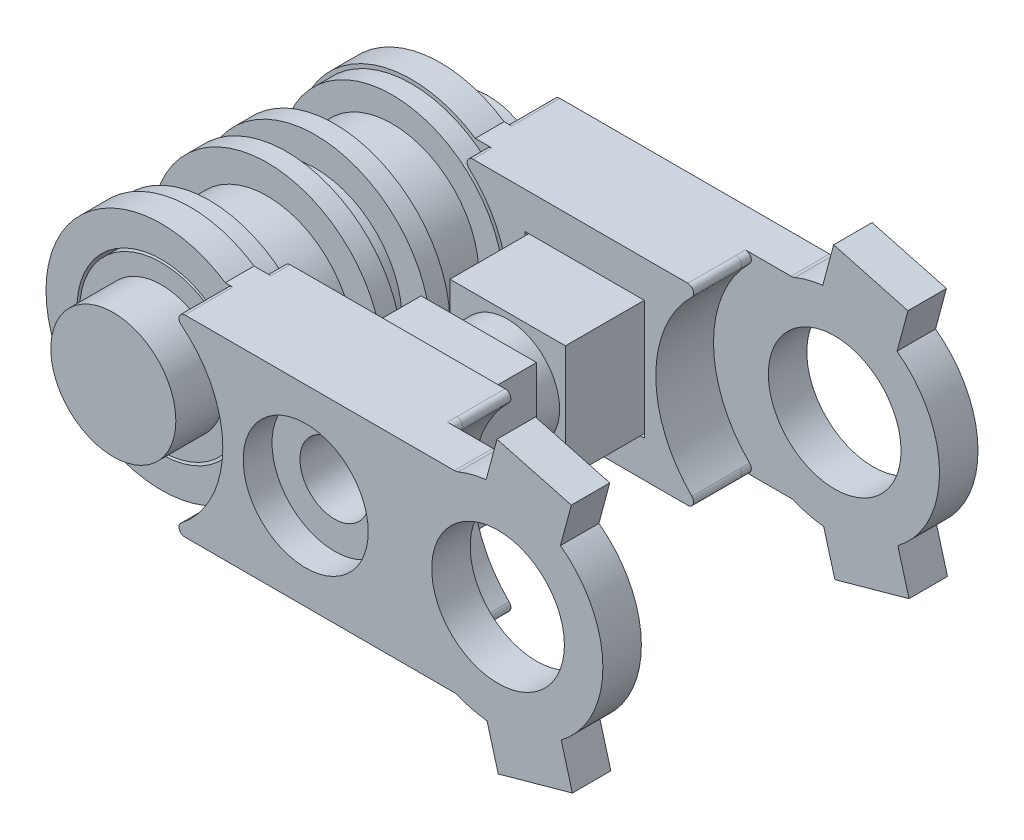
from build123d import *

# Parameters (mm, degrees)
SKETCH_1_R               = 4.5
EXTRUDE_1_DEPTH          = 3
SKETCH_2_R               = 6
EXTRUDE_2_DEPTH          = 1
EXTRUDE_START            = 1.5
SKETCH_3_R               = 4.5
EXTRUDE_3_DEPTH          = 1.5
SKETCH_4_R               = 6.000000000000001
EXTRUDE_4_DEPTH          = 1
EXTRUDE_START_2          = 3
SKETCH_5_R               = 4.5
EXTRUDE_5_DEPTH          = 3
SKETCH_6_R               = 6.000000000000001
EXTRUDE_6_DEPTH          = 1
EXTRUDE_START_3          = 1
SKETCH_7_R               = 6.000000000000001
EXTRUDE_7_DEPTH          = 1
SKETCH_10_R              = 4.25
EXTRUDE_10_DEPTH         = 1.5
SKETCH_11_R              = 3.25
EXTRUDE_11_DEPTH         = 2.5
SKETCH_12_R              = 4.390000000000002
EXTRUDE_12_DEPTH         = 1.5
EXTRUDE_13_DEPTH         = 0.5
FILLET_9_R               = 0.3
SKETCH_14_R              = 3.450000000000003
EXTRUDE_14_DEPTH         = 2
EXTRUDE_15_DEPTH         = 1
SKETCH_16_R              = 1.799999999999999
CUT_EXTRUDE_1_DEPTH      = 33.61828474950821
CUT_EXTRUDE_2_DEPTH      = 2
EXTRUDE_16_DEPTH         = 11.5
SKETCH_19_R              = 1.799999999999999
CUT_EXTRUDE_3_DEPTH      = 30.89903844607716
CUT_EXTRUDE_4_DEPTH      = 0.75
CUT_EXTRUDE_4_DEPTH_BACK = 0.75
SKETCH_20_R              = 2.6999999999999993
SKETCH_21_R              = 3.2500000000000027
CUT_EXTRUDE_5_DEPTH      = 1.5
CUT_EXTRUDE_6_DEPTH      = 1
EXTRUDE_17_DEPTH         = 2
EXTRUDE_18_DEPTH         = 2
SKETCH_26_R              = 6.000000000000001
SKETCH_26_R_2            = 5.800000000000002
CUT_EXTRUDE_8_DEPTH      = 31.24094733315028
SKETCH_27_R              = 6.000000000000001
SKETCH_27_R_2            = 5.8000000000000025
CUT_EXTRUDE_9_DEPTH      = 31.24094733315028


with BuildPart() as part:
    # ｽｹｯﾁ1 → ﾎﾞｽ - 押し出し1 (new body)
    with BuildSketch(Plane.XY):
        Circle(SKETCH_1_R)
    extrude(amount=EXTRUDE_1_DEPTH)

    # ｽｹｯﾁ2 → ﾎﾞｽ - 押し出し2 (add)
    with BuildSketch(Plane(origin=(0, 0, 0), x_dir=(-1, 0, 0), z_dir=(0, 0, -1))):
        Circle(SKETCH_2_R)
    extrude(amount=EXTRUDE_2_DEPTH)

    # ｽｹｯﾁ3 → ﾎﾞｽ - 押し出し3 (add)
    with BuildSketch(Plane(origin=(0, 0, -1), x_dir=(-1, 0, 0), z_dir=(0, 0, -1)).offset(EXTRUDE_START)):
        with Locations(Location((0, 0, 0), (0, 0, 180))):
            Circle(SKETCH_3_R)
    extrude(amount=-EXTRUDE_3_DEPTH)

    # ｽｹｯﾁ4 → ﾎﾞｽ - 押し出し4 (add)
    with BuildSketch(Plane(origin=(0, 0, -2.5), x_dir=(-1, 0, 0), z_dir=(0, 0, -1))):
        Circle(SKETCH_4_R)
    extrude(amount=EXTRUDE_4_DEPTH)

    # ｽｹｯﾁ5 → ﾎﾞｽ - 押し出し5 (add)
    with BuildSketch(Plane(origin=(0, 0, -3.5), x_dir=(-1, 0, 0), z_dir=(0, 0, -1)).offset(EXTRUDE_START_2)):
        with Locations(Location((0, 0, 0), (0, 0, 180))):
            Circle(SKETCH_5_R)
    extrude(amount=-EXTRUDE_5_DEPTH)

    # ｽｹｯﾁ6 → ﾎﾞｽ - 押し出し6 (add)
    with BuildSketch(Plane(origin=(0, 0, -6.500000000000001), x_dir=(-1, 0, 0), z_dir=(0, 0, -1))):
        Circle(SKETCH_6_R)
    extrude(amount=EXTRUDE_6_DEPTH)

    # ｽｹｯﾁ7 → ﾎﾞｽ - 押し出し7 (add)
    with BuildSketch(Plane.XY.offset(3).offset(EXTRUDE_START_3)):
        with Locations(Location((0, 0, 0), (0, 0, 180))):
            Circle(SKETCH_7_R)
    extrude(amount=-EXTRUDE_7_DEPTH)

    # ｽｹｯﾁ10 → ﾎﾞｽ - 押し出し10 (add)
    with BuildSketch(Plane.XY.offset(4)):
        Circle(SKETCH_10_R)
    extrude_10 = extrude(amount=EXTRUDE_10_DEPTH)

    # ｽｹｯﾁ11 → ﾎﾞｽ - 押し出し11 (add)
    with BuildSketch(Plane.XY.offset(5.5)):
        Circle(SKETCH_11_R)
    extrude_11 = extrude(amount=EXTRUDE_11_DEPTH)

    # ﾐﾗｰ1: ﾎﾞｽ - 押し出し10, ﾎﾞｽ - 押し出し11 across plane
    add(extrude_10.mirror(Plane.XY.offset(-1.7500000000000002)))
    add(extrude_11.mirror(Plane.XY.offset(-1.7500000000000002)))

    # ｽｹｯﾁ26 → ｶｯﾄ - 押し出し8 (cut, through all)
    with BuildSketch(Plane(origin=(0, 0, 3), x_dir=(-1, 0, 0), z_dir=(0, 0, -1))):
        Circle(SKETCH_26_R)
        Circle(SKETCH_26_R_2, mode=Mode.SUBTRACT)
    extrude(amount=-CUT_EXTRUDE_8_DEPTH, mode=Mode.SUBTRACT)

    # ｽｹｯﾁ27 → ｶｯﾄ - 押し出し9 (cut, through all)
    with BuildSketch(Plane.XY.offset(-6.500000000000001)):
        with Locations(Location((0, 0, 0), (0, 0, 180))):
            Circle(SKETCH_27_R)
        with Locations(Location((0, 0, 0), (0, 0, 180))):
            Circle(SKETCH_27_R_2, mode=Mode.SUBTRACT)
    extrude(amount=-CUT_EXTRUDE_9_DEPTH, mode=Mode.SUBTRACT)


with BuildPart() as body_2:
    # ｽｹｯﾁ12 → ﾎﾞｽ - 押し出し12 (new body)
    with BuildSketch(Plane.XY.offset(4)):
        with BuildLine():
            Line((3.3166247903554016, 5), (16.167246420652642, 5))
            ThreePointArc((16.167246420652642, 5), (13.700000000000001, 3.57e-15), (16.16724642065264, -5))
            Line((16.16724642065264, -5), (3.3166247903553985, -5.000000000000003))
            ThreePointArc((3.3166247903553985, -5.000000000000003), (-6.000000000000001, 7.3e-16), (3.3166247903554016, 5))
        make_face()
        Circle(SKETCH_12_R, mode=Mode.SUBTRACT)
    extrude(amount=EXTRUDE_12_DEPTH)

    # ｽｹｯﾁ13 → ﾎﾞｽ - 押し出し13 (add)
    with BuildSketch(Plane.XY.offset(5.5)):
        with BuildLine():
            Line((15.366426864718767, 5.000000000000001), (3.71350238992787, 4.999999999999999))
            ThreePointArc((3.71350238992787, 4.999999999999999), (3.4301142319534543, 4.798443648448575), (3.5275172952737197, 4.464607679465777))
            ThreePointArc((3.5275172952737197, 4.464607679465777), (5.69, 3.16e-15), (3.527517295273725, -4.464607679465773))
            ThreePointArc((3.527517295273725, -4.464607679465773), (3.4301142319534588, -4.798443648448569), (3.713502389927875, -4.9999999999999964))
            Line((3.713502389927875, -4.9999999999999964), (15.366426864718758, -4.999999999999996))
            ThreePointArc((15.366426864718758, -4.999999999999996), (15.643997494550977, -4.813818036595895), (15.57704382541336, -4.486363636363631))
            ThreePointArc((15.57704382541336, -4.486363636363631), (13.7, 6.37e-15), (15.577043825413366, 4.486363636363639))
            ThreePointArc((15.577043825413366, 4.486363636363639), (15.643997494550984, 4.813818036595901), (15.366426864718767, 5.000000000000001))
        make_face()
    extrude(amount=EXTRUDE_13_DEPTH)

    # ﾌｨﾚｯﾄ9
    fillet_9_edges = [body_2.edges().sort_by_distance(p)[0] for p in [
        (16.16724642065264, -5.000000000000001, 4.75),
        (16.167246420652642, 5, 4.75),
    ]]
    fillet(fillet_9_edges, radius=FILLET_9_R)

    # ｽｹｯﾁ14 → ﾎﾞｽ - 押し出し14 (add)
    with BuildSketch(Plane.XY.offset(6)):
        with BuildLine():
            Line((3.71350238992787, 5), (17.73008810743677, 5))
            ThreePointArc((17.73008810743677, 5), (17.827318665969592, 5.00954488636839), (17.920837005971492, 5.03781512605042))
            ThreePointArc((17.920837005971492, 5.03781512605042), (25.45, 2.42e-15), (17.920837005971496, -5.037815126050422))
            ThreePointArc((17.920837005971496, -5.037815126050422), (17.827318665969596, -5.009544886368393), (17.730088107436774, -5.000000000000003))
            Line((17.730088107436774, -5.000000000000003), (3.713502389927875, -5.000000000000003))
            ThreePointArc((3.713502389927875, -5.000000000000003), (3.430114231953458, -4.79844364844857), (3.5275172952737246, -4.4646076794657725))
            ThreePointArc((3.5275172952737246, -4.4646076794657725), (5.69, 3.16e-15), (3.52751729527372, 4.464607679465777))
            ThreePointArc((3.52751729527372, 4.464607679465777), (3.4301142319534534, 4.798443648448575), (3.71350238992787, 5))
        make_face()
        with Locations((20, 0)):
            Circle(SKETCH_14_R, mode=Mode.SUBTRACT)
    extrude(amount=EXTRUDE_14_DEPTH)

    # ｽｹｯﾁ15 → ﾎﾞｽ - 押し出し15 (add)
    with BuildSketch(Plane(origin=(0, 0, 4), x_dir=(-1, 0, 0), z_dir=(0, 0, -1))):
        with BuildLine():
            Line((-15.366426864718765, 5), (-4.195235392680607, 5.000000000000001))
            ThreePointArc((-4.195235392680607, 5.000000000000001), (-3.9149294373899135, 4.806904496764971), (-3.9954622787434353, 4.476190476190477))
            ThreePointArc((-3.9954622787434353, 4.476190476190477), (-6.000000000000001, 7.3e-16), (-3.9954622787434353, -4.476190476190477))
            ThreePointArc((-3.9954622787434353, -4.476190476190477), (-3.9149294373899135, -4.806904496764971), (-4.195235392680607, -5.000000000000001))
            Line((-4.195235392680607, -5.000000000000001), (-15.366426864718763, -5))
            ThreePointArc((-15.366426864718763, -5), (-15.643997494550984, -4.813818036595896), (-15.577043825413359, -4.48636363636363))
            ThreePointArc((-15.577043825413359, -4.48636363636363), (-13.700000000000001, 4.2e-15), (-15.577043825413364, 4.486363636363636))
            ThreePointArc((-15.577043825413364, 4.486363636363636), (-15.643997494550984, 4.813818036595898), (-15.366426864718765, 5))
        make_face()
    extrude(amount=EXTRUDE_15_DEPTH)


with BuildPart() as body_3:
    # ﾐﾗｰ2: mirrored copy
    add(body_2.part.mirror(Plane.XY.offset(-1.7500000000000002)))


with BuildPart() as cut_extrude_1_tool:
    # ｽｹｯﾁ16 → ｶｯﾄ - 押し出し1 (new, through all)
    with BuildSketch(Plane.XY.offset(8)):
        with Locations((10, 0)):
            Circle(SKETCH_16_R)
    extrude(amount=-CUT_EXTRUDE_1_DEPTH)


with BuildPart() as body_2_1:
    add(body_2.part)

    # ｶｯﾄ - 押し出し1: cut by cut_extrude_1_tool
    add(cut_extrude_1_tool.part, mode=Mode.SUBTRACT)

    # ｽｹｯﾁ18 → ﾎﾞｽ - 押し出し16 (add)
    with BuildSketch(Plane(origin=(0, 0, 3), x_dir=(-1, 0, 0), z_dir=(0, 0, -1))):
        Polygon((-7.000000000000002, 2.9999999999999996), (-13.000000000000002, 2.9999999999999987), (-13.000000000000002, -2.9999999999999996), (-7.000000000000002, -2.999999999999999), align=None)
    extrude(amount=EXTRUDE_16_DEPTH)

    # ｽｹｯﾁ19 → ｶｯﾄ - 押し出し3 (cut, through all)
    with BuildSketch(Plane.XY.offset(3)):
        with Locations((10, 0)):
            Circle(SKETCH_19_R)
    extrude(amount=-CUT_EXTRUDE_3_DEPTH, mode=Mode.SUBTRACT)

    # ｽｹｯﾁ20 → ｶｯﾄ - 押し出し4 (cut, two sides: drawn at the far end of the back side and taken through both)
    with BuildSketch(Plane.XY.offset(-1.7500000000000002).offset(-CUT_EXTRUDE_4_DEPTH_BACK)):
        Polygon((13.000000000000002, 2.9999999999999987), (7.000000000000002, 2.9999999999999996), (7.000000000000002, -2.999999999999999), (13.000000000000002, -2.9999999999999996), align=None)
        with Locations((10, 0)):
            Circle(SKETCH_20_R, mode=Mode.SUBTRACT)
    extrude(amount=CUT_EXTRUDE_4_DEPTH + CUT_EXTRUDE_4_DEPTH_BACK, mode=Mode.SUBTRACT)

    # ｽｹｯﾁ21 → ｶｯﾄ - 押し出し5 (cut)
    with BuildSketch(Plane.XY.offset(8)):
        with Locations((10, 0)):
            Circle(SKETCH_21_R)
    extrude(amount=-CUT_EXTRUDE_5_DEPTH, mode=Mode.SUBTRACT)

    # ｽｹｯﾁ23 → ﾎﾞｽ - 押し出し17 (add)
    with BuildSketch(Plane.XY.offset(8)):
        Polygon((19.012837862046062, 4.043267356160144), (22.87654116720234, 3.0079911757500586), (23.808289729571413, 6.485324150390705), (19.94458642441514, 7.520600330800791), align=None)
        Polygon((20.010217320150122, -7.52079753791903), (23.864739132984617, -6.451844033605999), (22.902680979102882, -2.9827744020549556), (19.04815916626839, -4.051727906367987), align=None)
    extrude(amount=-EXTRUDE_17_DEPTH)


with BuildPart() as body_3_1:
    add(body_3.part)

    # ｶｯﾄ - 押し出し1: cut by cut_extrude_1_tool
    add(cut_extrude_1_tool.part, mode=Mode.SUBTRACT)

    # ｽｹｯﾁ17 → ｶｯﾄ - 押し出し2 (cut)
    with BuildSketch(Plane.XY.offset(-6.500000000000001)):
        Polygon((13.100000000000001, -3.0999999999999996), (6.900000000000001, -3.1000000000000005), (6.900000000000001, 3.0999999999999996), (13.100000000000001, 3.1000000000000005), align=None)
    extrude(amount=-CUT_EXTRUDE_2_DEPTH, mode=Mode.SUBTRACT)

    # ｽｹｯﾁ22 → ｶｯﾄ - 押し出し6 (cut)
    with BuildSketch(Plane(origin=(0, 0, -11.5), x_dir=(-1, 0, 0), z_dir=(0, 0, -1))):
        Polygon((-11.674315780649914, 2.8999999999999995), (-13.348631561299829, 1e-17), (-11.674315780649913, -2.900000000000001), (-8.325684219350087, -2.9000000000000004), (-6.651368438700171, -8.7e-16), (-8.325684219350087, 2.9), align=None)
    extrude(amount=-CUT_EXTRUDE_6_DEPTH, mode=Mode.SUBTRACT)

    # ｽｹｯﾁ24 → ﾎﾞｽ - 押し出し18 (add)
    with BuildSketch(Plane(origin=(0, 0, -11.5), x_dir=(-1, 0, 0), z_dir=(0, 0, -1))):
        Polygon((-22.87654116720234, 3.0079911757500586), (-19.012837862046062, 4.043267356160144), (-19.94458642441514, 7.520600330800791), (-23.808289729571413, 6.485324150390705), align=None)
        Polygon((-23.864739132984617, -6.451844033605999), (-20.010217320150122, -7.52079753791903), (-19.04815916626839, -4.051727906367987), (-22.902680979102882, -2.9827744020549556), align=None)
    extrude(amount=-EXTRUDE_18_DEPTH)


solid = Compound([part.part, body_2_1.part, body_3_1.part])
